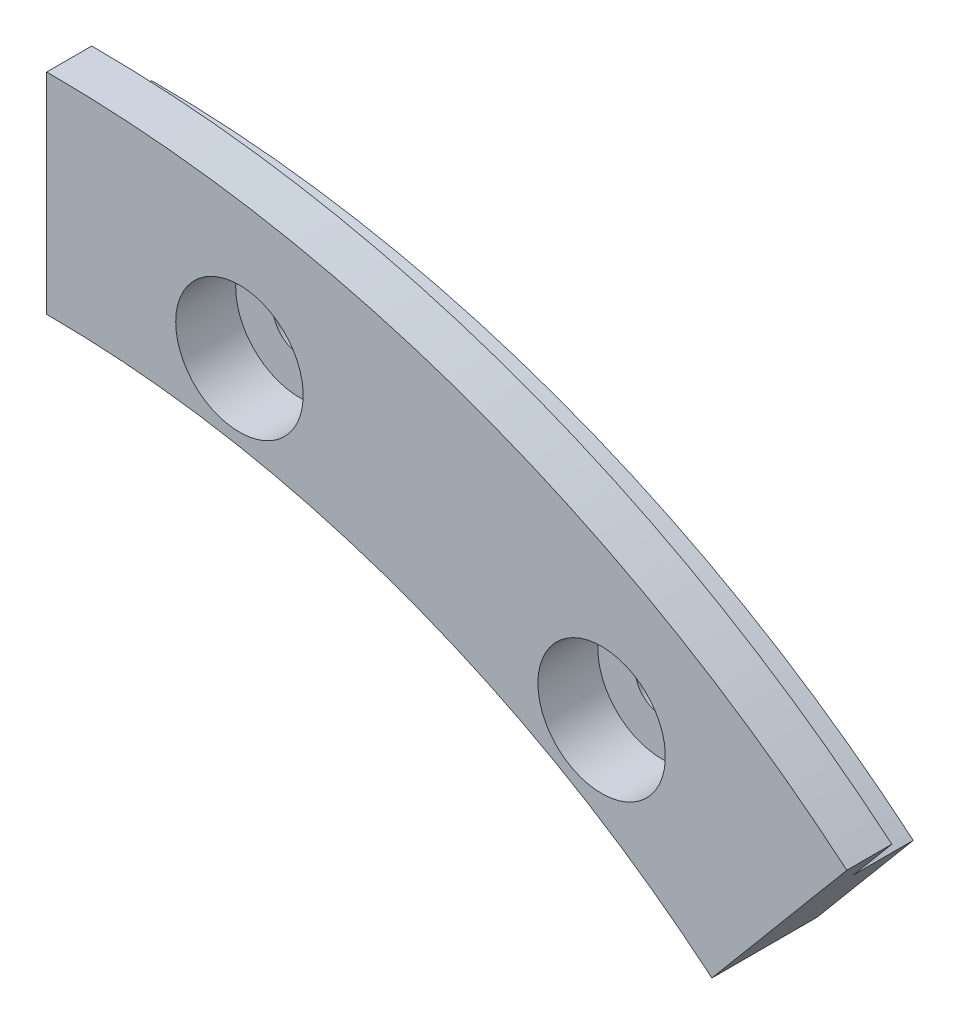
from build123d import *

# Parameters (mm, degrees)
BOSS_EXTRUDE1_DEPTH = 4
BOSS_EXTRUDE2_DEPTH = 3
SKETCH4_R           = 1.75
CUT_EXTRUDE1_DEPTH  = 8
SKETCH5_R           = 4.25
CUT_EXTRUDE2_DEPTH  = 4


with BuildPart() as part:
    # Sketch1 → Boss-Extrude1 (new body)
    with BuildSketch(Plane.XY):
        with BuildLine():
            Line((0, 79), (0, 69))
            ThreePointArc((0, 69), (23.599389889, 64.838790834), (44.352345068, 52.857066575))
            Line((44.352345068, 52.857066575), (50.780221165, 60.517511006))
            ThreePointArc((50.780221165, 60.517511006), (27.019591323, 74.235717042), (0, 79))
        make_face()
    extrude(amount=BOSS_EXTRUDE1_DEPTH)

    # Sketch2 → Boss-Extrude2 (add)
    with BuildSketch(Plane.XY.offset(4)):
        with BuildLine():
            Line((44.352345068, 52.857066575), (53.351371604, 63.581688779))
            ThreePointArc((53.351371604, 63.581688779), (28.387671896, 77.994487525), (0, 83))
            Line((0, 83), (0, 69))
            ThreePointArc((0, 69), (23.599389889, 64.838790834), (44.352345068, 52.857066575))
        make_face()
    extrude(amount=BOSS_EXTRUDE2_DEPTH)

    # Sketch4 → Cut-Extrude1 (cut, through all)
    with BuildSketch(Plane.XY.offset(7)):
        with Locations((12.849965147, 72.875773723)):
            Circle(SKETCH4_R)
        with Locations((37, 64.08587988)):
            Circle(SKETCH4_R)
    extrude(amount=-CUT_EXTRUDE1_DEPTH, mode=Mode.SUBTRACT)

    # Sketch5 → Cut-Extrude2 (cut)
    with BuildSketch(Plane(origin=(0, 0, 7), x_dir=(-1, 0, 0), z_dir=(0, 0, -1))):
        with Locations((-37, 64.08587988)):
            Circle(SKETCH5_R)
        with Locations((-12.849965147, 72.875773723)):
            Circle(SKETCH5_R)
    extrude(amount=CUT_EXTRUDE2_DEPTH, mode=Mode.SUBTRACT)


solid = part.part
